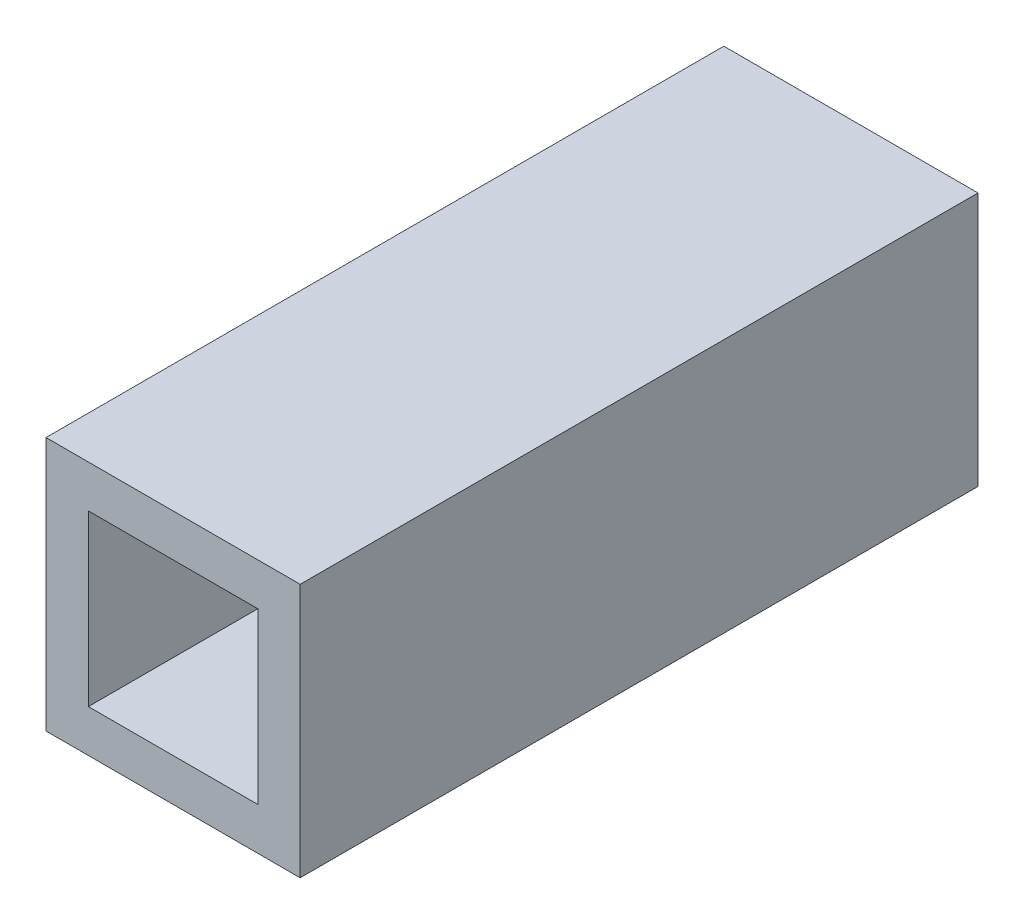
from build123d import *

# Parameters (mm, degrees)
SKETCH1_W           = 19.05
SKETCH1_H           = 19.05
BOSS_EXTRUDE1_DEPTH = 50.8
CUT_EXTRUDE1_REACH  = 52.8
SKETCH2_W           = 12.7
SKETCH2_H           = 12.7


with BuildPart() as part:
    # Sketch1 → Boss-Extrude1 (new body)
    with BuildSketch(Plane.XY):
        Rectangle(SKETCH1_W, SKETCH1_H)
    extrude(amount=-BOSS_EXTRUDE1_DEPTH)

    # Sketch2 → Cut-Extrude1 (cut, up to next)
    with BuildSketch(Plane.XY, mode=Mode.PRIVATE) as cut_extrude1_sk1:
        Rectangle(SKETCH2_W, SKETCH2_H)
    cut_extrude1_tool1 = extrude(cut_extrude1_sk1.sketch, amount=-CUT_EXTRUDE1_REACH, mode=Mode.PRIVATE) & part.part
    add(cut_extrude1_tool1.solids().sort_by_distance((0, 0, 0))[0], mode=Mode.SUBTRACT)


solid = part.part
